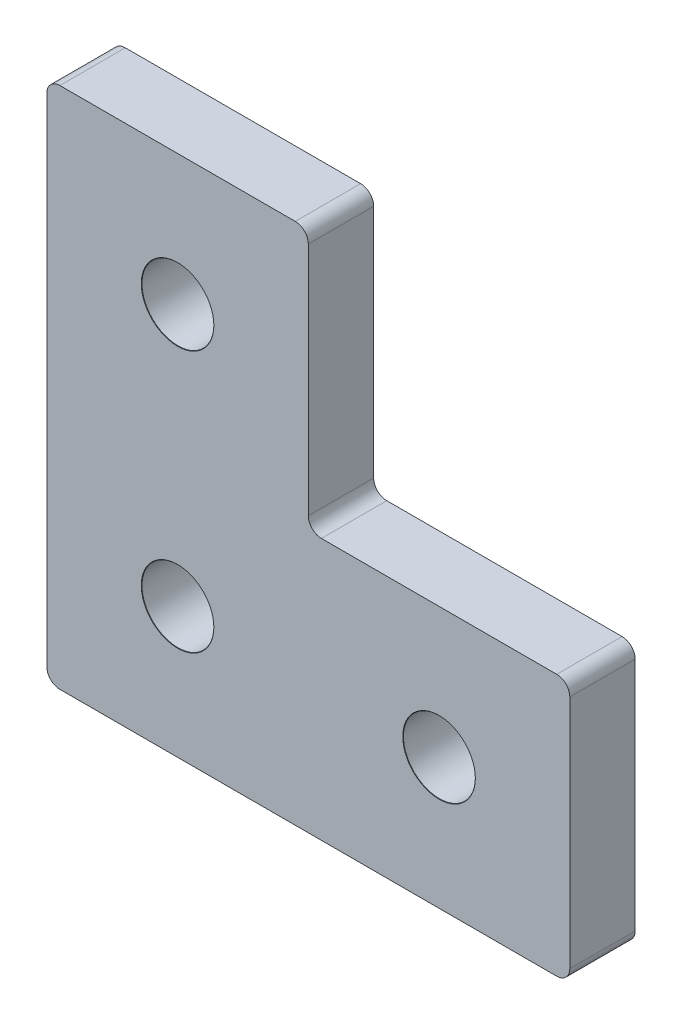
from build123d import *

# Parameters (mm, degrees)
BOSS_EXTRUDE1_DEPTH            = 5
M5_CLEARANCE_HOLE1_D           = 5.5
M5_CLEARANCE_HOLE1_CSINK_D     = 5.55
M5_CLEARANCE_HOLE1_CSINK_ANGLE = 90


with BuildPart() as part:
    # Sketch1 → Boss-Extrude1 (new body)
    with BuildSketch(Plane.XY):
        with BuildLine():
            Line((1, 0), (39, 0))
            ThreePointArc((39, 0), (39.707106781, 0.292893219), (40, 1))
            Line((40, 1), (40, 19))
            ThreePointArc((40, 19), (39.707106781, 19.707106781), (39, 20))
            Line((39, 20), (21, 20))
            ThreePointArc((21, 20), (20.292893219, 20.292893219), (20, 21))
            Line((20, 21), (20, 39))
            ThreePointArc((20, 39), (19.707106781, 39.707106781), (19, 40))
            Line((19, 40), (1, 40))
            ThreePointArc((1, 40), (0.292893219, 39.707106781), (0, 39))
            Line((0, 39), (0, 1))
            ThreePointArc((0, 1), (0.292893219, 0.292893219), (1, 0))
        make_face()
    extrude(amount=BOSS_EXTRUDE1_DEPTH)

    # M5 Clearance Hole1 (through all)
    with Locations(Plane.XY.offset(5)):
        with Locations((10, 30), (10, 10), (30, 10)):
            CounterSinkHole(M5_CLEARANCE_HOLE1_D / 2, M5_CLEARANCE_HOLE1_CSINK_D / 2, counter_sink_angle=M5_CLEARANCE_HOLE1_CSINK_ANGLE)


solid = part.part
